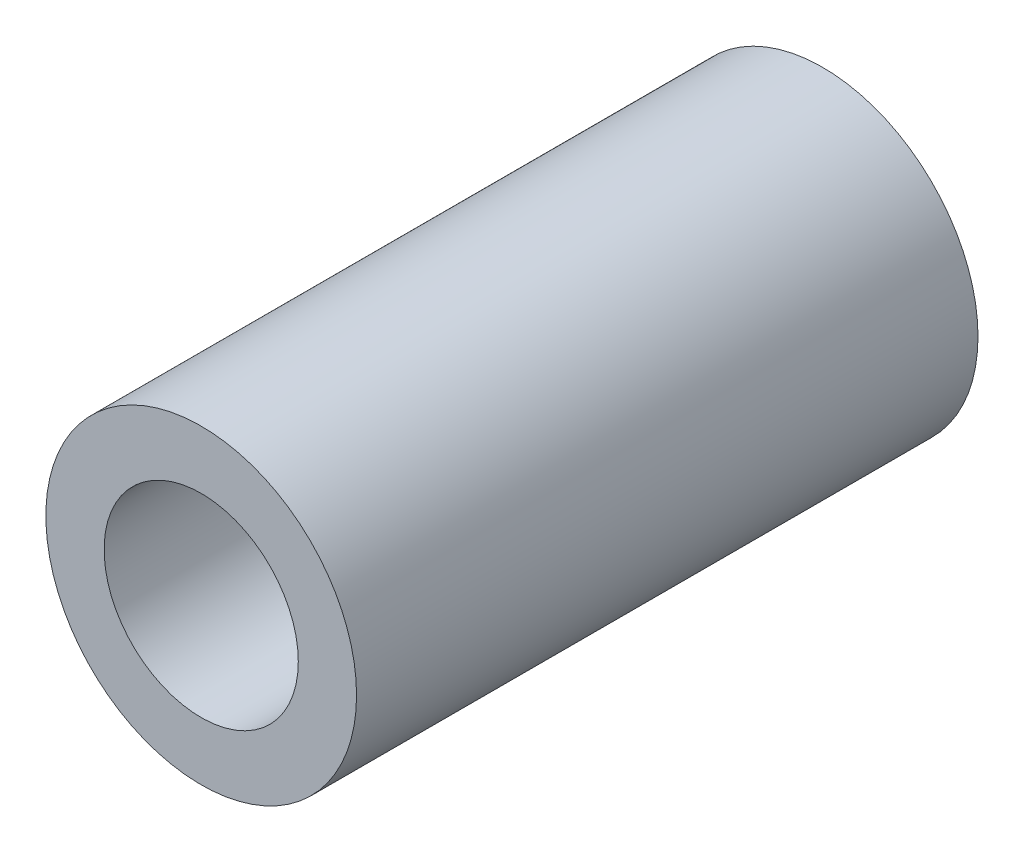
from build123d import *

# Parameters (mm, degrees)
SKETCH1_R           = 1.5875
BOSS_EXTRUDE1_DEPTH = 6.35
CUT_EXTRUDE1_REACH  = 8.35
SKETCH2_R           = 0.9921875


with BuildPart() as part:
    # Sketch1 → Boss-Extrude1 (new body)
    with BuildSketch(Plane.XY):
        Circle(SKETCH1_R)
    extrude(amount=BOSS_EXTRUDE1_DEPTH)

    # Sketch2 → Cut-Extrude1 (cut, up to next)
    with BuildSketch(Plane.XY.offset(6.35), mode=Mode.PRIVATE) as cut_extrude1_sk1:
        Circle(SKETCH2_R)
    cut_extrude1_tool1 = extrude(cut_extrude1_sk1.sketch, amount=-CUT_EXTRUDE1_REACH, mode=Mode.PRIVATE) & part.part
    add(cut_extrude1_tool1.solids().sort_by_distance((0, 0, 6.35))[0], mode=Mode.SUBTRACT)


solid = part.part
